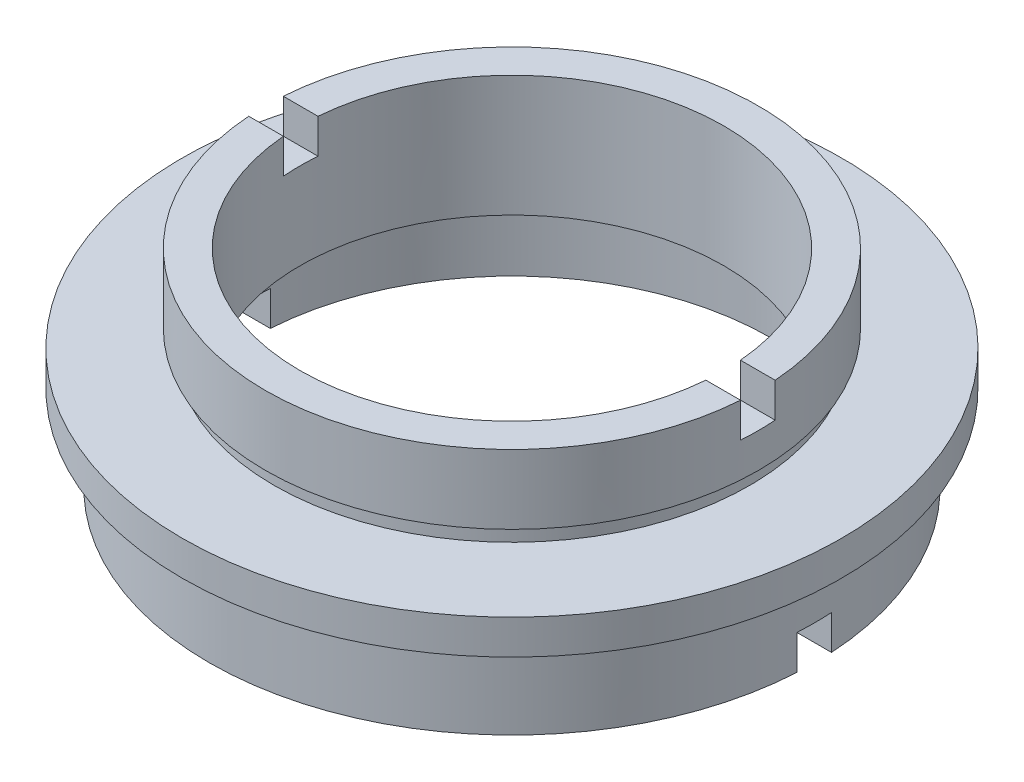
from build123d import *

# Parameters (mm, degrees)
SKETCH_2_W          = 2
SKETCH_2_H          = 3.593987872
SKETCH_2_H_2        = 6.667892238
CUT_EXTRUDE_1_DEPTH = 39.5


with BuildPart() as part:
    # 草图1 → 旋转1 (revolve)
    with BuildSketch(Plane.XY, mode=Mode.PRIVATE) as revolve_1_sk:
        Polygon((-12.25, 12), (-14.25, 12), (-14.25, 8), (-13.75, 8), (-13.75, 7), (-19.05, 7), (-19.05, 5), (-17, 5), (-17, 4), (-17.5, 4), (-17.5, 0), (-15, 0), (-15, 4), (-15.6, 4), (-15.6, 5), (-12.25, 5), align=None)
    revolve(revolve_1_sk.sketch.rotate(Axis((0, 22.677499451, 0), (0, -1, 0)), 270), axis=Axis((0, 22.677499451, 0), (0, -1, 0)))  # turned: the seam where the file's is

    # 草图2 → 切除-拉伸1 (cut, symmetric)
    with BuildSketch(Plane(origin=(0, 0, 0), x_dir=(0, 0, -1), z_dir=(1, 0, 0))):
        with Locations((0, 11.796993936)):
            Rectangle(SKETCH_2_W, SKETCH_2_H)
        with Locations((0, -1.333946119)):
            Rectangle(SKETCH_2_W, SKETCH_2_H_2)
    extrude(amount=CUT_EXTRUDE_1_DEPTH, both=True, mode=Mode.SUBTRACT)


solid = part.part
